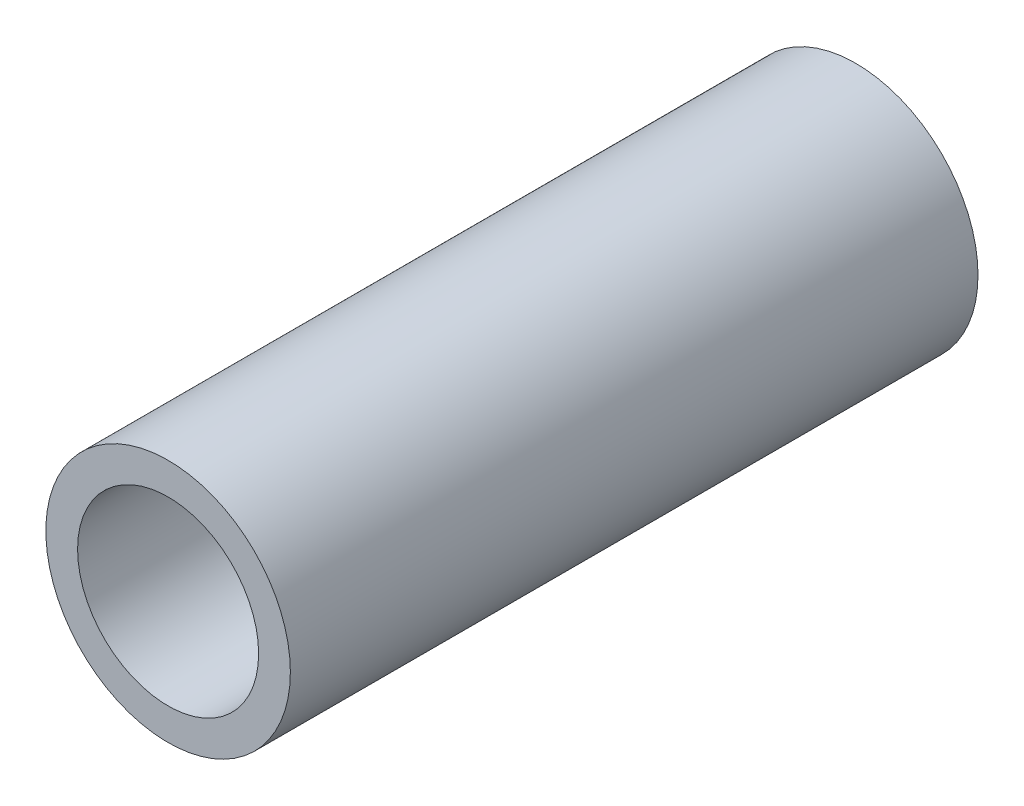
from build123d import *

# Parameters (mm, degrees)
SKETCH1_R           = 10.668
SKETCH1_R_2         = 7.8994
EXTRUDE_THIN1_DEPTH = 30


with BuildPart() as part:
    # Sketch1 → Extrude-Thin1 (new body, symmetric)
    with BuildSketch(Plane.XY):
        Circle(SKETCH1_R)
        Circle(SKETCH1_R_2, mode=Mode.SUBTRACT)
    extrude(amount=EXTRUDE_THIN1_DEPTH, both=True)


solid = part.part
